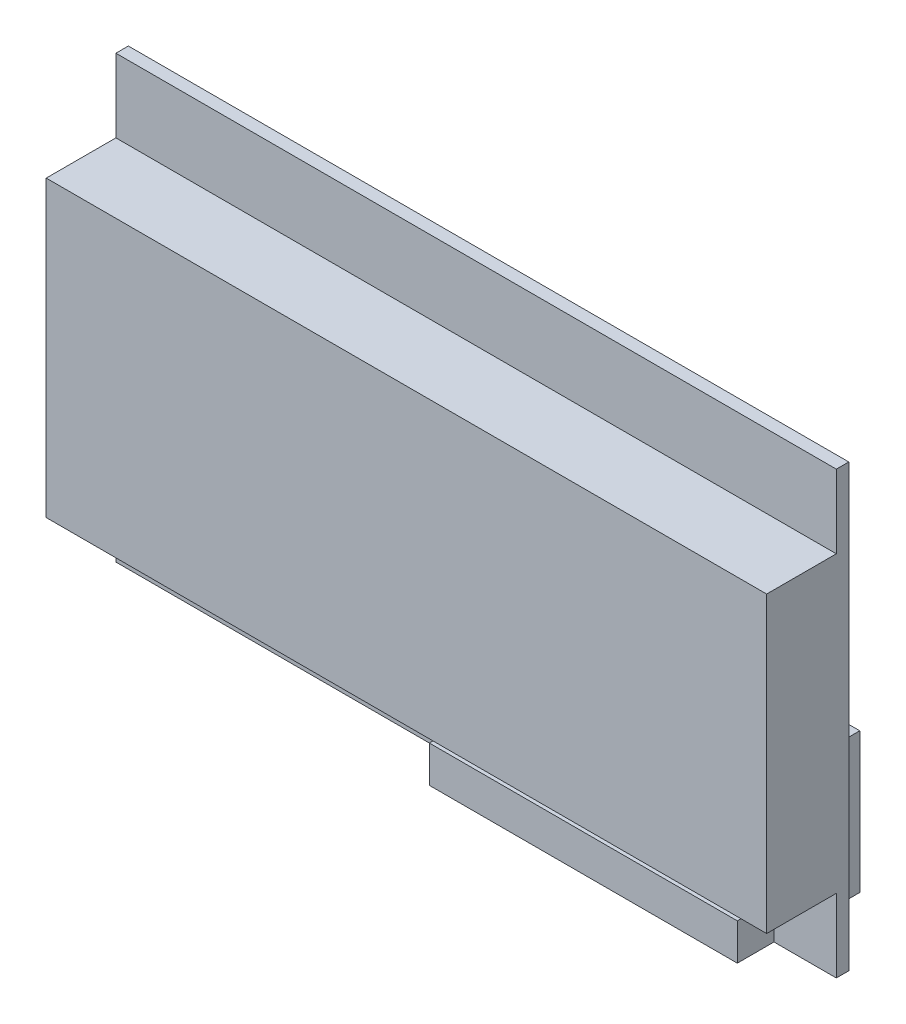
from build123d import *

# Parameters (mm, degrees)
SKETCH_1_W      = 98.25
SKETCH_1_H      = 60.1
EXTRUDE_1_DEPTH = 1.7
SKETCH_2_W      = 98.25
SKETCH_2_H      = 40.1
EXTRUDE_2_DEPTH = 9.5
SKETCH_3_W      = 42
SKETCH_3_H      = 5
EXTRUDE_3_DEPTH = 5
SKETCH_4_W      = 42
SKETCH_4_H      = 19.1
EXTRUDE_4_DEPTH = 10


with BuildPart() as part:
    # Эскиз1 → Бобышка-Вытянуть1 (new body)
    with BuildSketch(Plane.XY):
        with Locations((49.125, 30.05)):
            Rectangle(SKETCH_1_W, SKETCH_1_H)
    extrude(amount=EXTRUDE_1_DEPTH)

    # Эскиз2 → Бобышка-Вытянуть2 (add)
    with BuildSketch(Plane.XY.offset(1.7)):
        with Locations((49.125, 30.05)):
            Rectangle(SKETCH_2_W, SKETCH_2_H)
    extrude(amount=EXTRUDE_2_DEPTH)

    # Эскиз3 → Бобышка-Вытянуть3 (add)
    with BuildSketch(Plane.XY.offset(1.7)):
        with Locations((68.75, 2.5)):
            Rectangle(SKETCH_3_W, SKETCH_3_H)
    extrude(amount=EXTRUDE_3_DEPTH)

    # Эскиз4 → Бобышка-Вытянуть4 (add)
    with BuildSketch(Plane(origin=(0, 0, 0), x_dir=(-1, 0, 0), z_dir=(0, 0, -1))):
        with Locations((-68.75, 9.55)):
            Rectangle(SKETCH_4_W, SKETCH_4_H)
    extrude(amount=EXTRUDE_4_DEPTH)


solid = part.part
